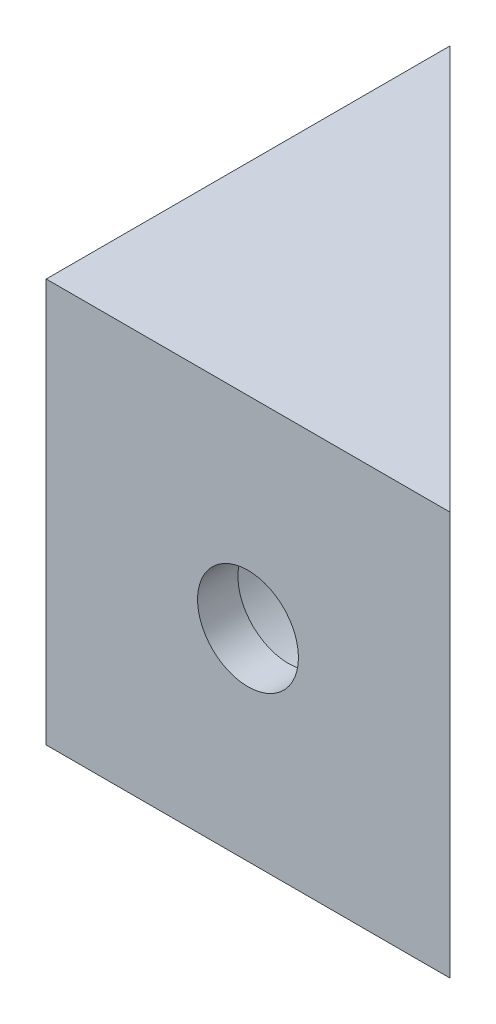
from build123d import *

# Parameters (mm, degrees)
BOSS_EXTRUDE1_DEPTH = 20
SKETCH2_R           = 2.5
CUT_EXTRUDE1_DEPTH  = 21
SKETCH3_R           = 2.5
CUT_EXTRUDE2_DEPTH  = 21
CUT_EXTRUDE3_START  = -2
SKETCH4_R           = 5
CUT_EXTRUDE3_DEPTH  = 19
CUT_EXTRUDE4_START  = -2
SKETCH5_R           = 5
CUT_EXTRUDE4_DEPTH  = 20


with BuildPart() as part:
    # Sketch1 → Boss-Extrude1 (new body)
    with BuildSketch(Plane(origin=(0, 0, 0), x_dir=(1, 0, 0), z_dir=(0, 1, 0))):
        Polygon((0, 0), (0, 20), (20, 0), align=None)
    extrude(amount=BOSS_EXTRUDE1_DEPTH)

    # Sketch2 → Cut-Extrude1 (cut, through all)
    with BuildSketch(Plane.XY):
        with Locations((10, 10)):
            Circle(SKETCH2_R)
    extrude(amount=-CUT_EXTRUDE1_DEPTH, mode=Mode.SUBTRACT)

    # Sketch3 → Cut-Extrude2 (cut, through all)
    with BuildSketch(Plane.ZY):
        with Locations((-10, 10)):
            Circle(SKETCH3_R)
    extrude(amount=-CUT_EXTRUDE2_DEPTH, mode=Mode.SUBTRACT)

    # Sketch4 → Cut-Extrude3 (cut, through all)
    with BuildSketch(Plane.ZY.offset(CUT_EXTRUDE3_START)):
        with Locations((-10, 10)):
            Circle(SKETCH4_R)
    extrude(amount=-CUT_EXTRUDE3_DEPTH, mode=Mode.SUBTRACT)

    # Sketch5 → Cut-Extrude4 (cut)
    with BuildSketch(Plane.XY.offset(CUT_EXTRUDE4_START)):
        with Locations((10, 10)):
            Circle(SKETCH5_R)
    extrude(amount=-CUT_EXTRUDE4_DEPTH, mode=Mode.SUBTRACT)


solid = part.part
